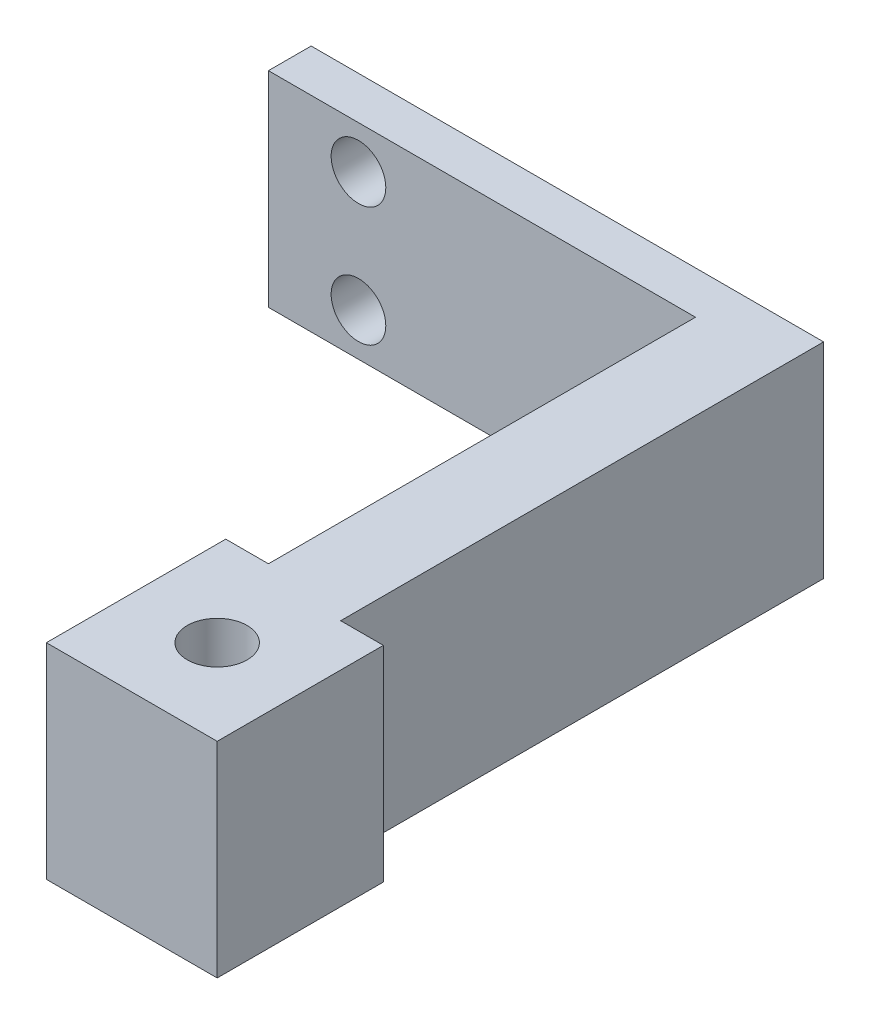
from build123d import *

# Parameters (mm, degrees)
SKETCH1_R           = 1.75
BOSS_EXTRUDE1_DEPTH = 12
SKETCH3_R           = 1.6
CUT_EXTRUDE1_DEPTH  = 3.5
BOSS_EXTRUDE2_DEPTH = 12


with BuildPart() as part:
    # Sketch1 → Boss-Extrude1 (new body)
    with BuildSketch(Plane(origin=(0, 0, 0), x_dir=(1, 0, 0), z_dir=(0, 1, 0))):
        Polygon((-1.649648438, 29.291322314), (-1.649648438, -3.708677686), (3.350351562, -3.708677686), (3.350351562, 31.791322314), (-26.649648438, 31.791322314), (-26.649648438, 29.291322314), align=None)
        with Locations((0.850351562, -1.208677686)):
            Circle(SKETCH1_R, mode=Mode.SUBTRACT)
    extrude(amount=BOSS_EXTRUDE1_DEPTH)

    # Sketch3 → Cut-Extrude1 (cut, through all)
    with BuildSketch(Plane.XY.offset(-29.291322314)):
        with Locations((-21.379789069, 2.5)):
            Circle(SKETCH3_R)
        with Locations((-21.379789069, 9.5)):
            Circle(SKETCH3_R)
    extrude(amount=-CUT_EXTRUDE1_DEPTH, mode=Mode.SUBTRACT)

    # Sketch4 → Boss-Extrude2 (add, through all)
    with BuildSketch(Plane(origin=(0, 0, 0), x_dir=(1, 0, 0), z_dir=(0, 1, 0))):
        Polygon((-1.649648438, 4.291322314), (-4.149648438, 4.291322314), (-4.149648438, -6.208677686), (5.850351562, -6.208677686), (5.850351562, 3.519074646), (3.350351562, 3.519074646), (3.350351562, -3.708677686), (-1.649648438, -3.708677686), align=None)
    extrude(amount=BOSS_EXTRUDE2_DEPTH)


solid = part.part
